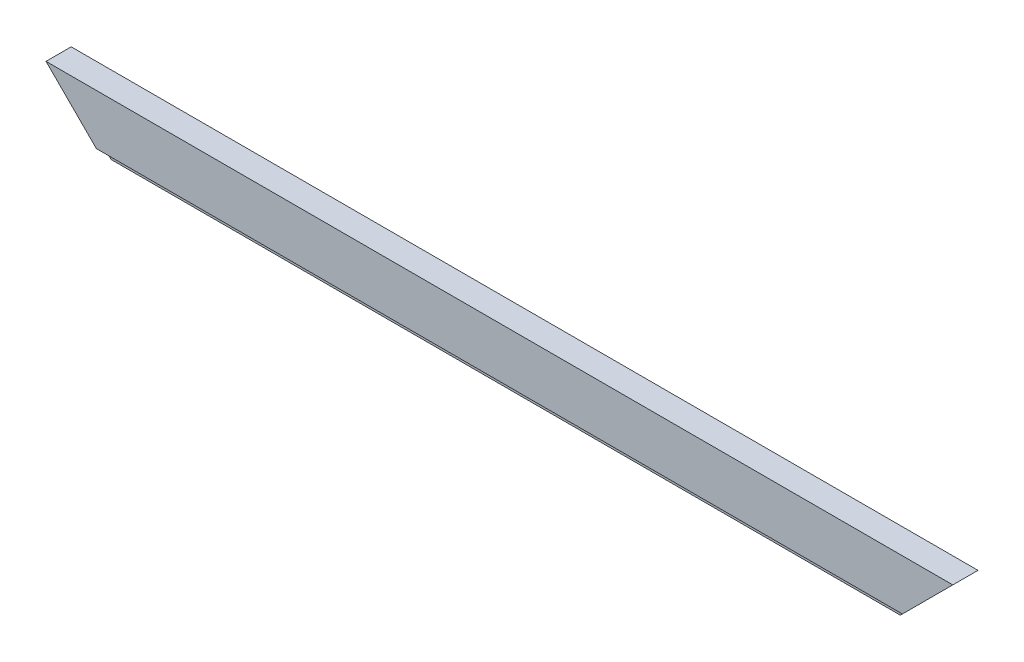
from build123d import *

# Parameters (mm, degrees)
SKETCH1_W           = 1371.6
SKETCH1_H           = 88.9
BOSS_EXTRUDE1_DEPTH = 38.1
CUT_EXTRUDE1_REACH  = 40.1
CUT_EXTRUDE2_REACH  = 40.1
CUT_EXTRUDE3_DEPTH  = 9.525


with BuildPart() as part:
    # Sketch1 → Boss-Extrude1 (new body)
    with BuildSketch(Plane.XY):
        with Locations((685.8, 44.45)):
            Rectangle(SKETCH1_W, SKETCH1_H)
    extrude(amount=BOSS_EXTRUDE1_DEPTH)

    # Sketch2 → Cut-Extrude1 (cut, up to next)
    with BuildSketch(Plane.XY.offset(38.1), mode=Mode.PRIVATE) as cut_extrude1_sk1:
        Polygon((0, 88.9), (88.9, 0), (0, 0), align=None)
    cut_extrude1_tool1 = extrude(cut_extrude1_sk1.sketch, amount=-CUT_EXTRUDE1_REACH, mode=Mode.PRIVATE) & part.part
    add(cut_extrude1_tool1.solids().sort_by_distance((29.633333, 29.633333, 38.1))[0], mode=Mode.SUBTRACT)

    # Sketch3 → Cut-Extrude2 (cut, up to next)
    with BuildSketch(Plane.XY.offset(38.1), mode=Mode.PRIVATE) as cut_extrude2_sk1:
        Polygon((1371.6, 88.9), (1282.7, 0), (1371.6, 0), align=None)
    cut_extrude2_tool1 = extrude(cut_extrude2_sk1.sketch, amount=-CUT_EXTRUDE2_REACH, mode=Mode.PRIVATE) & part.part
    add(cut_extrude2_tool1.solids().sort_by_distance((1341.966667, 29.633333, 38.1))[0], mode=Mode.SUBTRACT)

    # Sketch4 → Cut-Extrude3 (cut)
    with BuildSketch(Plane.XY.offset(38.1)):
        Polygon((88.9, 0), (1282.7, 0), (1295.4, 12.7), (76.2, 12.7), align=None)
    extrude(amount=-CUT_EXTRUDE3_DEPTH, mode=Mode.SUBTRACT)


solid = part.part
